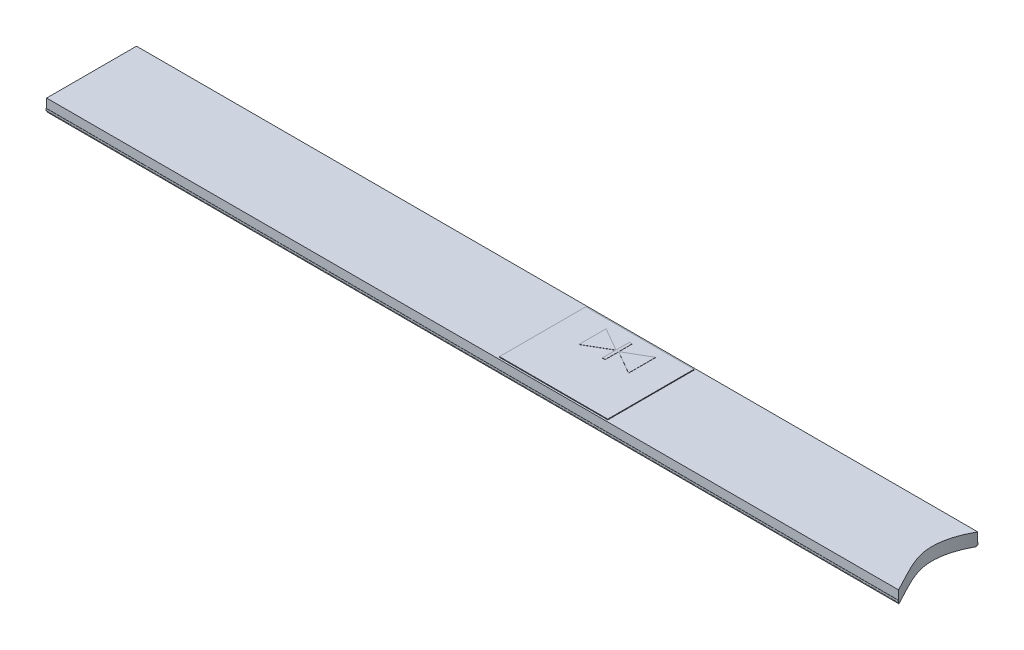
from build123d import *

# Parameters (mm, degrees)
EXTRUDE1_DEPTH = 100
SKETCH2_W      = 9.96
SKETCH2_H      = 1
SKETCH2_W_2    = 9.8
SKETCH2_H_2    = 0.1
EXTRUDE2_DEPTH = 0.05
EXTRUDE3_DEPTH = 2
SKETCH4_W      = 12
SKETCH4_H      = 9.559999993
EXTRUDE4_DEPTH = 0.08
EXTRUDE5_DEPTH = 0.02


with BuildPart() as part:
    # Sketch1 → Extrude1 (new body)
    with BuildSketch(Plane(origin=(0, 0, 0), x_dir=(0, 0, -1), z_dir=(1, 0, 0))):
        with BuildLine():
            Line((9.98, 0.3), (10, 0.3))
            Line((10, 0.3), (10, 0.1))
            ThreePointArc((10, 0.1), (9.970710678, 0.029289322), (9.9, 0))
            Line((9.9, 0), (9.9, -0.1))
            Line((9.9, -0.1), (0.1, -0.1))
            Line((0.1, -0.1), (0.1, 0))
            ThreePointArc((0.1, 0), (0.029289322, 0.029289322), (0, 0.1))
            Line((0, 0.1), (0, 0.3))
            Line((0, 0.3), (0.02, 0.3))
            Line((0.02, 0.3), (0.02, 1.3))
            Line((0.02, 1.3), (9.98, 1.3))
            Line((9.98, 1.3), (9.98, 0.3))
        make_face()
    extrude(amount=EXTRUDE1_DEPTH)

    # Sketch2 → Extrude2 (cut)
    with BuildSketch(Plane(origin=(0, 0, 0), x_dir=(0, 0, -1), z_dir=(1, 0, 0))):
        with Locations((5, 0.8)):
            Rectangle(SKETCH2_W, SKETCH2_H)
        with Locations((5, -0.05)):
            Rectangle(SKETCH2_W_2, SKETCH2_H_2)
    extrude(amount=EXTRUDE2_DEPTH, mode=Mode.SUBTRACT)

    # Sketch3 → Extrude3 (cut)
    with BuildSketch(Plane(origin=(0, 1.3, 0), x_dir=(1, 0, 0), z_dir=(0, 1, 0))):
        with BuildLine():
            add(Edge.make_bspline(
                [(106.958570584, 17.182100949), (111.37058159, 16.276136115), (117.385402068, 8.882986689), (109.774353113, -0.100316481), (120.943228088, -13.427718663), (86.89741128, -25.636712544), (98.859416736, -3.790829743), (87.550468543, 7.821814957), (100.083371056, 18.593858308), (106.958570584, 17.182100949)],
                knots=[0, 0, 0, 0, 0.128972817, 0.210070442, 0.3169221, 0.544532993, 0.707848036, 0.799022747, 1, 1, 1, 1], degree=3))
        make_face()
    extrude(amount=-EXTRUDE3_DEPTH, mode=Mode.SUBTRACT)

    # Sketch4 → Extrude4 (add)
    with BuildSketch(Plane(origin=(0, 1.3, 0), x_dir=(1, 0, 0), z_dir=(0, 1, 0))):
        with Locations((56.05, 5.000000004)):
            Rectangle(SKETCH4_W, SKETCH4_H)
    extrude(amount=EXTRUDE4_DEPTH)

    # Sketch5 → Extrude5 (add)
    with BuildSketch(Plane(origin=(0, 1.38, 0), x_dir=(1, 0, 0), z_dir=(0, 1, 0))):
        Polygon((55.9, 7.281184034), (53.303974596, 8.78), (53.303974596, 5.78), (55.9, 7.278815966), (55.9, 5.78), (56.2, 5.78), (56.2, 7.278815966), (58.796025404, 5.78), (58.796025404, 8.78), (56.2, 7.281184034), (56.2, 8.78), (55.9, 8.78), align=None)
    extrude(amount=EXTRUDE5_DEPTH)


solid = part.part
